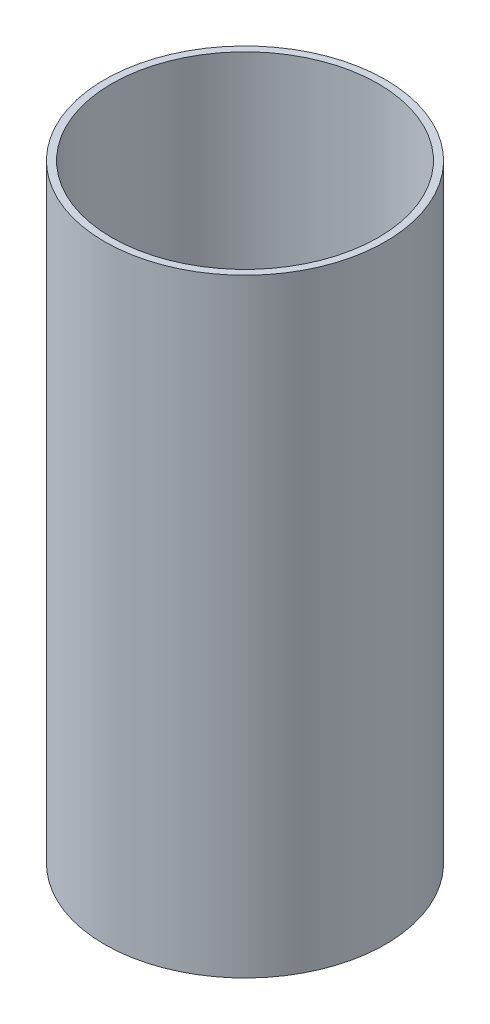
from build123d import *

# Parameters (mm, degrees)
SKETCH1_R           = 93.6625
SKETCH1_R_2         = 88.9
BOSS_EXTRUDE1_DEPTH = 202.97775


with BuildPart() as part:
    # Sketch1 → Boss-Extrude1 (new body, symmetric)
    with BuildSketch(Plane(origin=(0, 0, 0), x_dir=(1, 0, 0), z_dir=(0, 1, 0))):
        Circle(SKETCH1_R)
        Circle(SKETCH1_R_2, mode=Mode.SUBTRACT)
    extrude(amount=BOSS_EXTRUDE1_DEPTH, both=True)


solid = part.part
